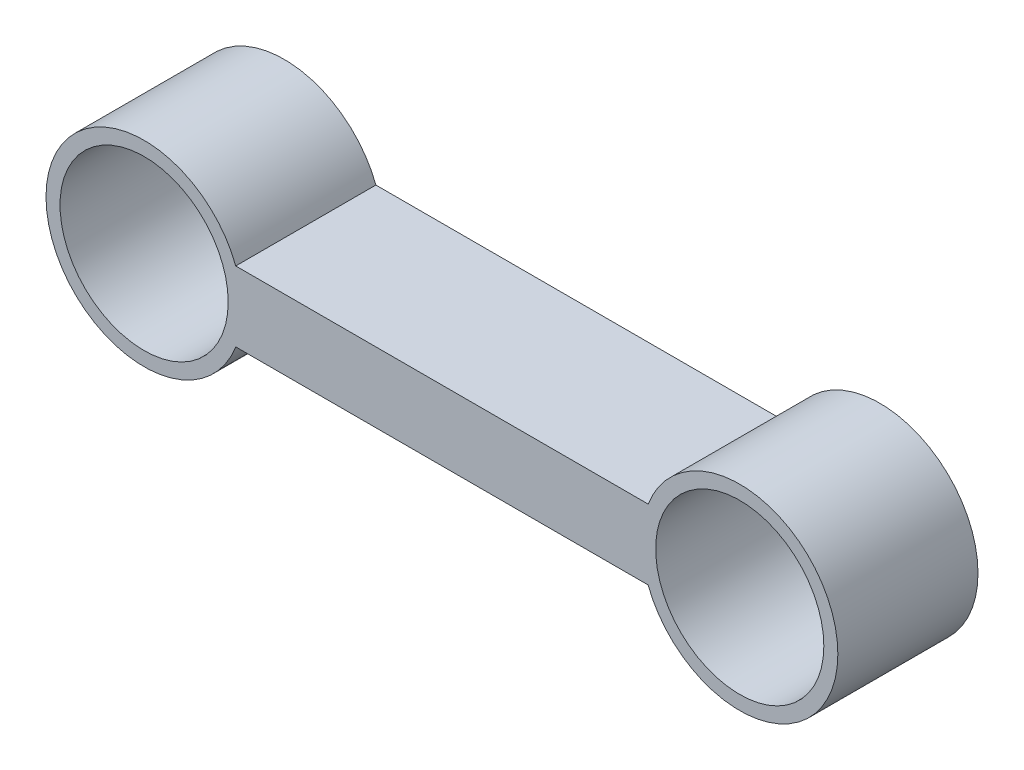
from build123d import *

# Parameters (mm, degrees)
SKETCH1_R           = 15.24
BOSS_EXTRUDE1_DEPTH = 25.4


with BuildPart() as part:
    # Sketch1 → Boss-Extrude1 (new body)
    with BuildSketch(Plane.XY):
        with BuildLine():
            ThreePointArc((16.607404975, 6.35), (-17.78, 0), (16.607404975, -6.35))
            Line((16.607404975, -6.35), (16.607404975, 6.35))
        make_face()
        Circle(SKETCH1_R, mode=Mode.SUBTRACT)
        with BuildLine():
            Line((16.607404975, -6.35), (91.342595025, -6.35))
            ThreePointArc((91.342595025, -6.35), (90.17, 0), (91.342595025, 6.35))
            Line((91.342595025, 6.35), (16.607404975, 6.35))
            ThreePointArc((16.607404975, 6.35), (17.484393905, 3.228679261), (17.78, 0))
            ThreePointArc((17.78, 0), (17.484393905, -3.228679261), (16.607404975, -6.35))
        make_face()
        with BuildLine():
            Line((16.607404975, 6.35), (16.607404975, -6.35))
            ThreePointArc((16.607404975, -6.35), (17.484393905, -3.228679261), (17.78, 0))
            ThreePointArc((17.78, 0), (17.484393905, 3.228679261), (16.607404975, 6.35))
        make_face()
        with BuildLine():
            Line((91.342595025, 6.35), (91.342595025, -6.35))
            ThreePointArc((91.342595025, -6.35), (111.178679261, -17.484393905), (125.73, 0))
            ThreePointArc((125.73, 0), (111.178679261, 17.484393905), (91.342595025, 6.35))
        make_face()
        with Locations((107.95, 0)):
            Circle(SKETCH1_R, mode=Mode.SUBTRACT)
        with BuildLine():
            ThreePointArc((91.342595025, 6.35), (90.17, 0), (91.342595025, -6.35))
            Line((91.342595025, -6.35), (91.342595025, 6.35))
        make_face()
    extrude(amount=BOSS_EXTRUDE1_DEPTH)


solid = part.part
